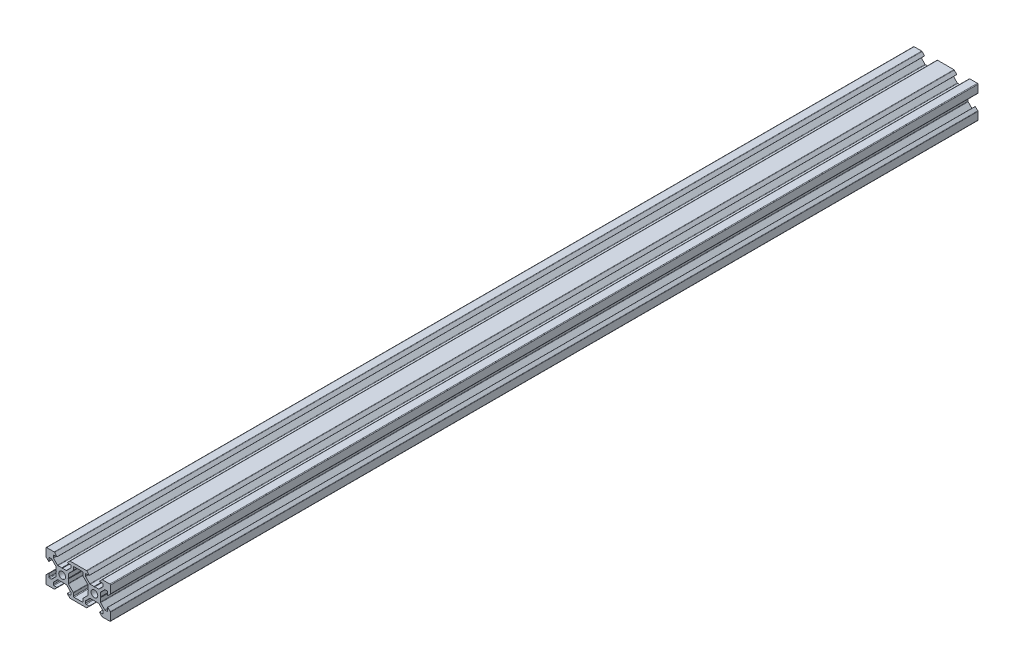
from build123d import *

# Parameters (mm, degrees)
SKETCH_1_R             = 2
EXTRUDE_1_DEPTH        = 538
HOLE_WIZARD_M5_1_D     = 4.2
HOLE_WIZARD_M5_1_DEPTH = 15
HOLE_WIZARD_M5_1_TIP   = 1.2618073
HOLE_WIZARD_M5_2_D     = 4.2
HOLE_WIZARD_M5_2_DEPTH = 15
HOLE_WIZARD_M5_2_TIP   = 1.2618073


with BuildPart() as part:
    # 草图1 → 凸台-拉伸1 (new body)
    with BuildSketch(Plane.XY):
        with BuildLine():
            Line((0.2, 3.8), (2.573654403, 3.8))
            ThreePointArc((2.573654403, 3.8), (2.726727776, 3.830448187), (2.856497116, 3.917157288))
            Line((2.856497116, 3.917157288), (5.382842712, 6.443502884))
            ThreePointArc((5.382842712, 6.443502884), (5.469551813, 6.573272224), (5.5, 6.726345597))
            Line((5.5, 6.726345597), (5.5, 7.8))
            ThreePointArc((5.5, 7.8), (5.382842712, 8.082842712), (5.1, 8.2))
            Line((5.1, 8.2), (3.2, 8.2))
            Line((3.2, 8.2), (3.16812307, 8.273206881))
            Line((3.16812307, 8.273206881), (4.656346981, 9.872492278))
            ThreePointArc((4.656346981, 9.872492278), (4.789482475, 9.966740311), (4.949174504, 10))
            Line((4.949174504, 10), (10, 10))
            Line((10, 10), (15.050825496, 10))
            ThreePointArc((15.050825496, 10), (15.210517525, 9.966740311), (15.343653019, 9.872492278))
            Line((15.343653019, 9.872492278), (16.83187693, 8.273206881))
            Line((16.83187693, 8.273206881), (16.8, 8.2))
            Line((16.8, 8.2), (14.9, 8.2))
            ThreePointArc((14.9, 8.2), (14.617157288, 8.082842712), (14.5, 7.8))
            Line((14.5, 7.8), (14.5, 6.726345597))
            ThreePointArc((14.5, 6.726345597), (14.530448187, 6.573272224), (14.617157288, 6.443502884))
            Line((14.617157288, 6.443502884), (17.143502884, 3.917157288))
            ThreePointArc((17.143502884, 3.917157288), (17.273272224, 3.830448187), (17.426345597, 3.8))
            Line((17.426345597, 3.8), (19.8, 3.8))
            Line((19.8, 3.8), (20, 3.6))
            Line((20, 3.6), (20.2, 3.8))
            Line((20.2, 3.8), (22.573654403, 3.8))
            ThreePointArc((22.573654403, 3.8), (22.726727776, 3.830448187), (22.856497116, 3.917157288))
            Line((22.856497116, 3.917157288), (25.382842708, 6.44350288))
            ThreePointArc((25.382842708, 6.44350288), (25.469551809, 6.57327222), (25.499999996, 6.726345593))
            Line((25.499999996, 6.726345593), (25.499999996, 7.8))
            ThreePointArc((25.499999996, 7.8), (25.382842708, 8.082842712), (25.099999996, 8.2))
            Line((25.099999996, 8.2), (23.2, 8.2))
            Line((23.2, 8.2), (23.16812307, 8.273206881))
            Line((23.16812307, 8.273206881), (24.656346981, 9.872492278))
            ThreePointArc((24.656346981, 9.872492278), (24.789482475, 9.966740311), (24.949174504, 10))
            Line((24.949174504, 10), (29.6, 10))
            ThreePointArc((29.6, 10), (29.882842712, 9.882842712), (30, 9.6))
            Line((30, 9.6), (30, 4.949174504))
            ThreePointArc((30, 4.949174504), (29.966740311, 4.789482475), (29.872492278, 4.656346981))
            Line((29.872492278, 4.656346981), (28.273206881, 3.16812307))
            Line((28.273206881, 3.16812307), (28.2, 3.2))
            Line((28.2, 3.2), (28.2, 5.1))
            ThreePointArc((28.2, 5.1), (28.082842712, 5.382842712), (27.8, 5.5))
            Line((27.8, 5.5), (26.726345597, 5.5))
            ThreePointArc((26.726345597, 5.5), (26.573272224, 5.469551813), (26.443502884, 5.382842712))
            Line((26.443502884, 5.382842712), (23.917157288, 2.856497116))
            ThreePointArc((23.917157288, 2.856497116), (23.830448187, 2.726727776), (23.8, 2.573654403))
            Line((23.8, 2.573654403), (23.8, 0.2))
            Line((23.8, 0.2), (23.6, 0))
            Line((23.6, 0), (23.8, -0.2))
            Line((23.8, -0.2), (23.8, -2.573654403))
            ThreePointArc((23.8, -2.573654403), (23.830448187, -2.726727776), (23.917157288, -2.856497116))
            Line((23.917157288, -2.856497116), (26.443502884, -5.382842712))
            ThreePointArc((26.443502884, -5.382842712), (26.573272224, -5.469551813), (26.726345596, -5.5))
            Line((26.726345596, -5.5), (27.8, -5.500000002))
            ThreePointArc((27.8, -5.500000002), (28.082842712, -5.382842714), (28.2, -5.100000002))
            Line((28.2, -5.100000002), (28.2, -3.2))
            Line((28.2, -3.2), (28.273206881, -3.16812307))
            Line((28.273206881, -3.16812307), (29.872492278, -4.656346981))
            ThreePointArc((29.872492278, -4.656346981), (29.966740311, -4.789482475), (30, -4.949174504))
            Line((30, -4.949174504), (30, -9.6))
            ThreePointArc((30, -9.6), (29.882842712, -9.882842712), (29.6, -10))
            Line((29.6, -10), (24.949174504, -10))
            ThreePointArc((24.949174504, -10), (24.789482475, -9.966740311), (24.656346981, -9.872492278))
            Line((24.656346981, -9.872492278), (23.16812307, -8.273206881))
            Line((23.16812307, -8.273206881), (23.2, -8.2))
            Line((23.2, -8.2), (25.1, -8.2))
            ThreePointArc((25.1, -8.2), (25.382842712, -8.082842712), (25.5, -7.8))
            Line((25.5, -7.8), (25.5, -6.726345597))
            ThreePointArc((25.5, -6.726345597), (25.469551813, -6.573272224), (25.382842712, -6.443502884))
            Line((25.382842712, -6.443502884), (22.856497116, -3.917157288))
            ThreePointArc((22.856497116, -3.917157288), (22.726727776, -3.830448187), (22.573654403, -3.8))
            Line((22.573654403, -3.8), (20.2, -3.8))
            Line((20.2, -3.8), (20, -3.6))
            Line((20, -3.6), (19.8, -3.8))
            Line((19.8, -3.8), (17.426345597, -3.8))
            ThreePointArc((17.426345597, -3.8), (17.273272224, -3.830448187), (17.143502884, -3.917157288))
            Line((17.143502884, -3.917157288), (14.617157288, -6.443502884))
            ThreePointArc((14.617157288, -6.443502884), (14.530448187, -6.573272224), (14.5, -6.726345597))
            Line((14.5, -6.726345597), (14.5, -7.8))
            ThreePointArc((14.5, -7.8), (14.617157288, -8.082842712), (14.9, -8.2))
            Line((14.9, -8.2), (16.8, -8.2))
            Line((16.8, -8.2), (16.83187693, -8.273206881))
            Line((16.83187693, -8.273206881), (15.343653019, -9.872492278))
            ThreePointArc((15.343653019, -9.872492278), (15.210517525, -9.966740311), (15.050825496, -10))
            Line((15.050825496, -10), (10, -10))
            Line((10, -10), (4.949174504, -10))
            ThreePointArc((4.949174504, -10), (4.789482475, -9.966740311), (4.656346981, -9.872492278))
            Line((4.656346981, -9.872492278), (3.16812307, -8.273206881))
            Line((3.16812307, -8.273206881), (3.2, -8.2))
            Line((3.2, -8.2), (5.1, -8.2))
            ThreePointArc((5.1, -8.2), (5.382842713, -8.082842713), (5.5, -7.8))
            Line((5.5, -7.8), (5.5, -6.726345597))
            ThreePointArc((5.5, -6.726345597), (5.469551813, -6.573272224), (5.382842712, -6.443502884))
            Line((5.382842712, -6.443502884), (2.856497116, -3.917157288))
            ThreePointArc((2.856497116, -3.917157288), (2.726727776, -3.830448187), (2.573654403, -3.8))
            Line((2.573654403, -3.8), (0.2, -3.8))
            Line((0.2, -3.8), (0, -3.6))
            Line((0, -3.6), (-0.2, -3.8))
            Line((-0.2, -3.8), (-2.573654403, -3.8))
            ThreePointArc((-2.573654403, -3.8), (-2.726727776, -3.830448187), (-2.856497116, -3.917157288))
            Line((-2.856497116, -3.917157288), (-5.382842712, -6.443502884))
            ThreePointArc((-5.382842712, -6.443502884), (-5.469551813, -6.573272224), (-5.5, -6.726345597))
            Line((-5.5, -6.726345597), (-5.5, -7.8))
            ThreePointArc((-5.5, -7.8), (-5.382842712, -8.082842712), (-5.1, -8.2))
            Line((-5.1, -8.2), (-3.2, -8.2))
            Line((-3.2, -8.2), (-3.16812307, -8.273206881))
            Line((-3.16812307, -8.273206881), (-4.656346981, -9.872492278))
            ThreePointArc((-4.656346981, -9.872492278), (-4.789482475, -9.966740311), (-4.949174504, -10))
            Line((-4.949174504, -10), (-9.6, -10))
            ThreePointArc((-9.6, -10), (-9.882842712, -9.882842712), (-10, -9.6))
            Line((-10, -9.6), (-10, -4.949174504))
            ThreePointArc((-10, -4.949174504), (-9.966740311, -4.789482475), (-9.872492278, -4.656346981))
            Line((-9.872492278, -4.656346981), (-8.273206881, -3.16812307))
            Line((-8.273206881, -3.16812307), (-8.2, -3.2))
            Line((-8.2, -3.2), (-8.2, -5.100000002))
            ThreePointArc((-8.2, -5.100000002), (-8.082842712, -5.382842714), (-7.8, -5.500000002))
            Line((-7.8, -5.500000002), (-6.726345596, -5.5))
            ThreePointArc((-6.726345596, -5.5), (-6.573272223, -5.469551813), (-6.443502884, -5.382842712))
            Line((-6.443502884, -5.382842712), (-3.917157288, -2.856497116))
            ThreePointArc((-3.917157288, -2.856497116), (-3.830448187, -2.726727776), (-3.8, -2.573654403))
            Line((-3.8, -2.573654403), (-3.8, -0.2))
            Line((-3.8, -0.2), (-3.6, 0))
            Line((-3.6, 0), (-3.8, 0.2))
            Line((-3.8, 0.2), (-3.8, 2.573654403))
            ThreePointArc((-3.8, 2.573654403), (-3.830448187, 2.726727776), (-3.917157288, 2.856497116))
            Line((-3.917157288, 2.856497116), (-6.443502884, 5.382842712))
            ThreePointArc((-6.443502884, 5.382842712), (-6.573272224, 5.469551813), (-6.726345597, 5.5))
            Line((-6.726345597, 5.5), (-7.8, 5.5))
            ThreePointArc((-7.8, 5.5), (-8.082842712, 5.382842712), (-8.2, 5.1))
            Line((-8.2, 5.1), (-8.2, 3.2))
            Line((-8.2, 3.2), (-8.273206881, 3.16812307))
            Line((-8.273206881, 3.16812307), (-9.872492278, 4.656346981))
            ThreePointArc((-9.872492278, 4.656346981), (-9.966740311, 4.789482475), (-10, 4.949174504))
            Line((-10, 4.949174504), (-10, 9.6))
            ThreePointArc((-10, 9.6), (-9.882842712, 9.882842712), (-9.6, 10))
            Line((-9.6, 10), (-4.949174504, 10))
            ThreePointArc((-4.949174504, 10), (-4.789482475, 9.966740311), (-4.656346981, 9.872492278))
            Line((-4.656346981, 9.872492278), (-3.16812307, 8.273206881))
            Line((-3.16812307, 8.273206881), (-3.2, 8.2))
            Line((-3.2, 8.2), (-5.099999996, 8.2))
            ThreePointArc((-5.099999996, 8.2), (-5.382842708, 8.082842712), (-5.499999996, 7.8))
            Line((-5.499999996, 7.8), (-5.499999996, 6.726345593))
            ThreePointArc((-5.499999996, 6.726345593), (-5.469551809, 6.57327222), (-5.382842708, 6.44350288))
            Line((-5.382842708, 6.44350288), (-2.856497116, 3.917157288))
            ThreePointArc((-2.856497116, 3.917157288), (-2.726727776, 3.830448187), (-2.573654403, 3.8))
            Line((-2.573654403, 3.8), (-0.2, 3.8))
            Line((-0.2, 3.8), (0, 3.6))
            Line((0, 3.6), (0.2, 3.8))
        make_face()
        Circle(SKETCH_1_R, mode=Mode.SUBTRACT)
        with Locations((20, 0)):
            Circle(SKETCH_1_R, mode=Mode.SUBTRACT)
        with BuildLine():
            Line((3.8, 0.2), (3.8, 2.573654403))
            ThreePointArc((3.8, 2.573654403), (3.830448187, 2.726727776), (3.917157288, 2.856497116))
            Line((3.917157288, 2.856497116), (6.875280951, 5.81462078))
            ThreePointArc((6.875280951, 5.81462078), (6.967586575, 5.952765908), (7, 6.115719198))
            Line((7, 6.115719198), (7, 7.774182533))
            ThreePointArc((7, 7.774182533), (7.124719049, 8.075280951), (7.425817467, 8.2))
            Line((7.425817467, 8.2), (12.574182533, 8.2))
            ThreePointArc((12.574182533, 8.2), (12.875280951, 8.075280951), (13, 7.774182533))
            Line((13, 7.774182533), (13, 6.115719198))
            ThreePointArc((13, 6.115719198), (13.032413425, 5.952765908), (13.124719049, 5.81462078))
            Line((13.124719049, 5.81462078), (16.082842712, 2.856497116))
            ThreePointArc((16.082842712, 2.856497116), (16.169551813, 2.726727776), (16.2, 2.573654403))
            Line((16.2, 2.573654403), (16.2, 0.2))
            Line((16.2, 0.2), (16.4, 0))
            Line((16.4, 0), (16.2, -0.2))
            Line((16.2, -0.2), (16.2, -2.573654403))
            ThreePointArc((16.2, -2.573654403), (16.169551813, -2.726727776), (16.082842712, -2.856497116))
            Line((16.082842712, -2.856497116), (13.124719049, -5.81462078))
            ThreePointArc((13.124719049, -5.81462078), (13.032413425, -5.952765908), (13, -6.115719198))
            Line((13, -6.115719198), (13, -7.774182533))
            ThreePointArc((13, -7.774182533), (12.875280951, -8.075280951), (12.574182533, -8.2))
            Line((12.574182533, -8.2), (7.425817467, -8.2))
            ThreePointArc((7.425817467, -8.2), (7.124719049, -8.075280951), (7, -7.774182533))
            Line((7, -7.774182533), (7, -6.115719198))
            ThreePointArc((7, -6.115719198), (6.967586575, -5.952765908), (6.875280951, -5.81462078))
            Line((6.875280951, -5.81462078), (3.917157288, -2.856497116))
            ThreePointArc((3.917157288, -2.856497116), (3.830448187, -2.726727776), (3.8, -2.573654403))
            Line((3.8, -2.573654403), (3.8, -0.2))
            Line((3.8, -0.2), (3.6, 0))
            Line((3.6, 0), (3.8, 0.2))
        make_face(mode=Mode.SUBTRACT)
    extrude(amount=EXTRUDE_1_DEPTH)

    # M5 螺纹孔1
    with Locations(Plane(origin=(0, 0, 0), x_dir=(-1, 0, 0), z_dir=(0, 0, -1))):
        with Locations((0, 0), (-20, 0), (-618.665704654, 229.337897605), (-600.319062145, 227.034520718)):
            Hole(HOLE_WIZARD_M5_1_D / 2, depth=HOLE_WIZARD_M5_1_DEPTH)
            with Locations((0, 0, -(HOLE_WIZARD_M5_1_DEPTH + HOLE_WIZARD_M5_1_TIP / 2))):  # 118° drill point
                Cone(0, HOLE_WIZARD_M5_1_D / 2, HOLE_WIZARD_M5_1_TIP, mode=Mode.SUBTRACT)

    # M5 螺纹孔2
    with Locations(Plane.XY.offset(538)):
        with Locations((0, 0), (20, 0)):
            Hole(HOLE_WIZARD_M5_2_D / 2, depth=HOLE_WIZARD_M5_2_DEPTH)
            with Locations((0, 0, -(HOLE_WIZARD_M5_2_DEPTH + HOLE_WIZARD_M5_2_TIP / 2))):  # 118° drill point
                Cone(0, HOLE_WIZARD_M5_2_D / 2, HOLE_WIZARD_M5_2_TIP, mode=Mode.SUBTRACT)


solid = part.part
